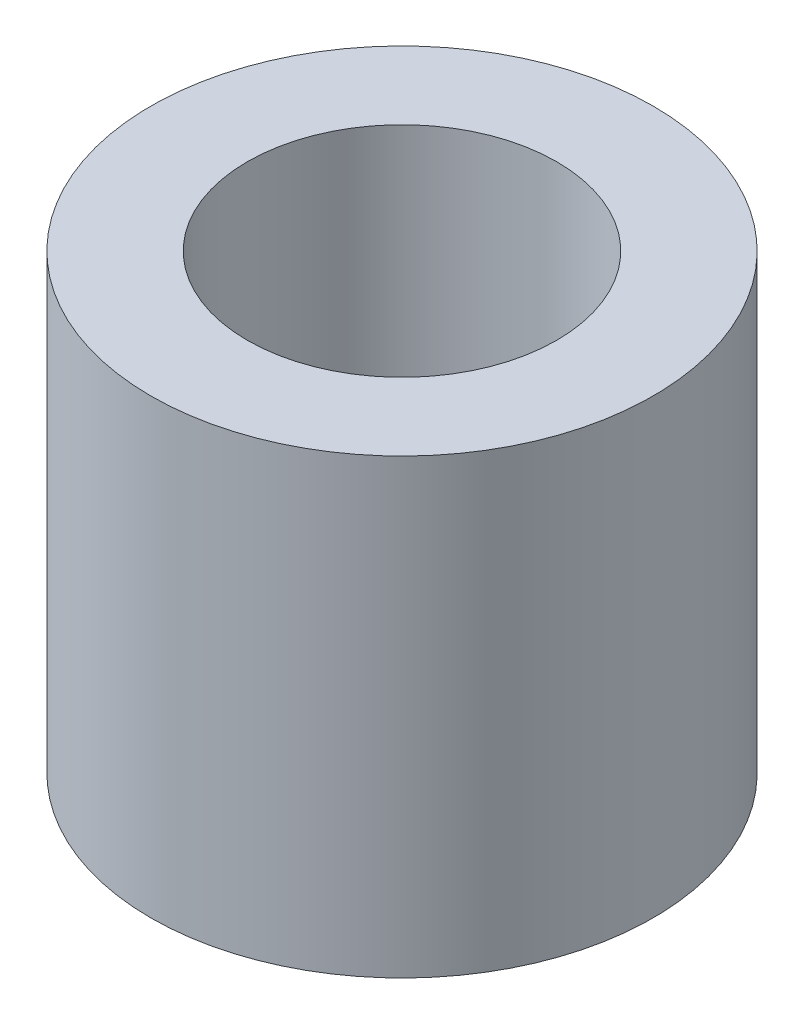
from build123d import *

# Parameters (mm, degrees)
SKETCH1_R           = 3.96875
SKETCH1_R_2         = 2.44475
BOSS_EXTRUDE1_DEPTH = 7.14375


with BuildPart() as part:
    # Sketch1 → Boss-Extrude1 (new body)
    with BuildSketch(Plane(origin=(0, 0, 0), x_dir=(1, 0, 0), z_dir=(0, 1, 0))):
        Circle(SKETCH1_R)
        Circle(SKETCH1_R_2, mode=Mode.SUBTRACT)
    extrude(amount=BOSS_EXTRUDE1_DEPTH)


solid = part.part
